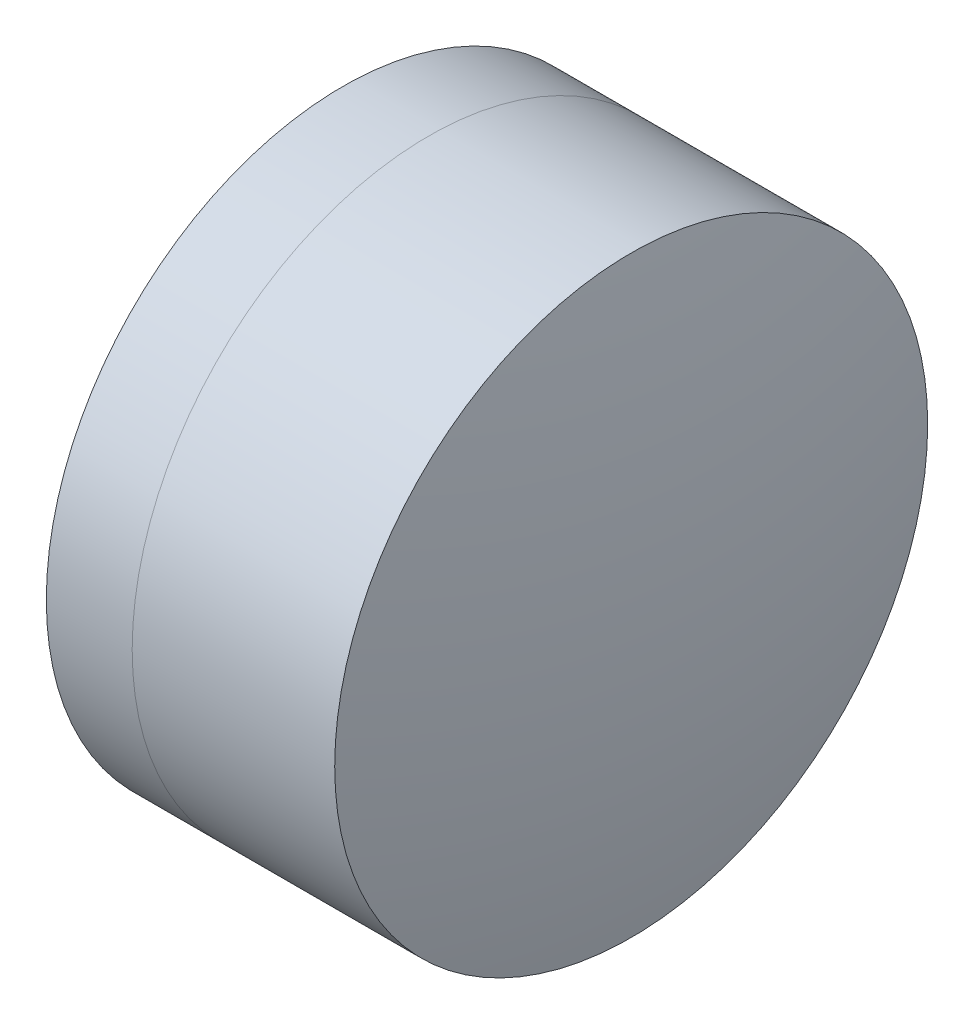
from build123d import *


with BuildPart() as part:
    # 草图1 one side → 旋转1 (revolve)
    with BuildSketch(Plane(origin=(0, 0, 0), x_dir=(1, 0, 0), z_dir=(0, 1, 0)), mode=Mode.PRIVATE) as revolve_1_sk:
        with BuildLine():
            ThreePointArc((-1.962826851, 4), (-2.546266763, 2.037703627), (-2.743175671, 0))
            Line((-2.743175671, 0), (0.436824329, 0))
            ThreePointArc((0.436824329, 0), (0.119395651, 2.094072853), (-0.804370438, 4))
            Line((-0.804370438, 4), (-1.962826851, 4))
        make_face()
    revolve(revolve_1_sk.sketch.rotate(Axis((-9.702612178, 0, 0), (1, 0, 0)), 180), axis=Axis((-9.702612178, 0, 0), (1, 0, 0)))  # turned: the seam where the file's is


with BuildPart() as body_2:
    # 草图2 one side → 旋转3 (revolve)
    with BuildSketch(Plane(origin=(0, 0, 0), x_dir=(1, 0, 0), z_dir=(0, 1, 0)), mode=Mode.PRIVATE) as revolve_3_sk:
        with BuildLine():
            Line((1.927975115, 4), (-0.804370438, 4))
            ThreePointArc((-0.804370438, 4), (0.119395651, 2.094072853), (0.436824329, 0))
            Line((0.436824329, 0), (2.356824329, 0))
            ThreePointArc((2.356824329, 0), (2.249305696, 2.011461636), (1.927975115, 4))
        make_face()
    revolve(revolve_3_sk.sketch.rotate(Axis((-0.551919993, 0, 0), (1, 0, 0)), 180), axis=Axis((-0.551919993, 0, 0), (1, 0, 0)))  # turned: the seam where the file's is


solid = Compound([part.part, body_2.part])
